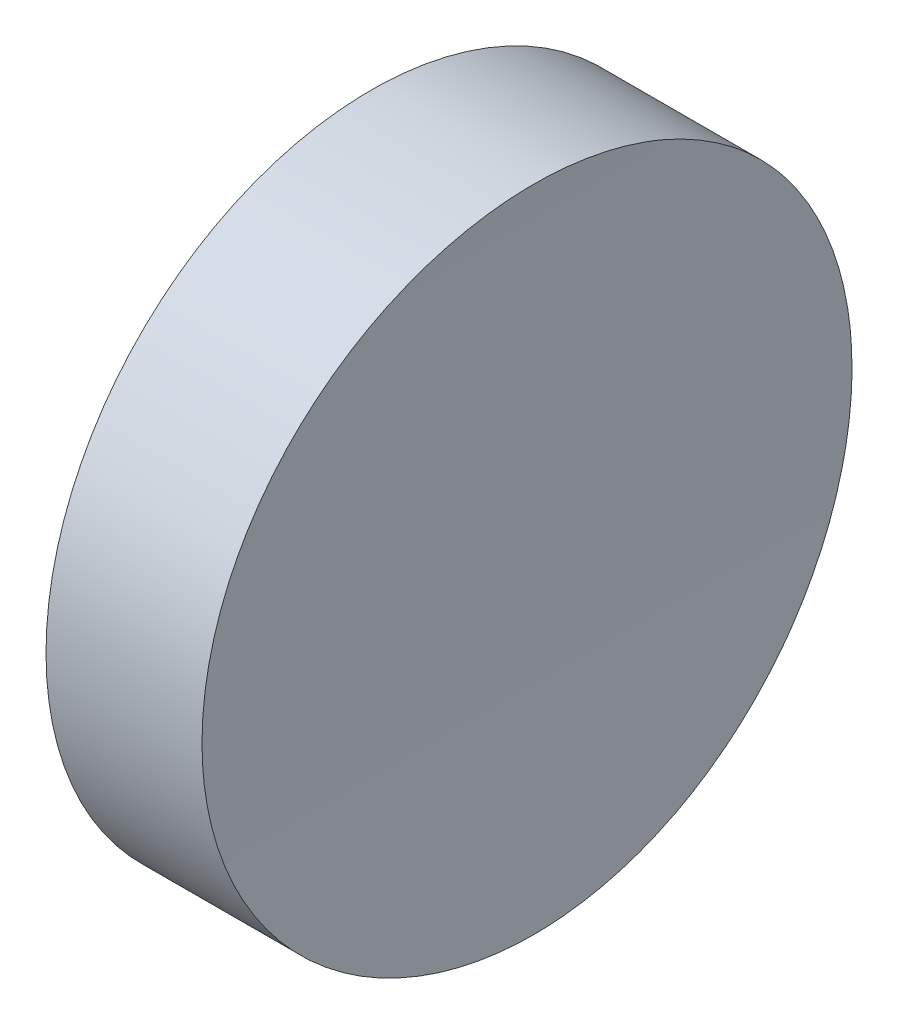
from build123d import *

# Parameters (mm, degrees)
SKETCH_1_R               = 6.25
EXTRUDE_1_DEPTH          = 10
SKETCH_2_R               = 150
CUT_EXTRUDE_1_DEPTH      = 7.25
CUT_EXTRUDE_1_DEPTH_BACK = 7.25


with BuildPart() as part:
    # 草图1 → 凸台-拉伸1 (new body)
    with BuildSketch(Plane(origin=(0, 0, 0), x_dir=(0, 0, -1), z_dir=(1, 0, 0))):
        Circle(SKETCH_1_R)
    extrude(amount=EXTRUDE_1_DEPTH)

    # 草图2 → 切除-拉伸1 (cut, two sides)
    with BuildSketch(Plane.XY) as cut_extrude_1_sk:
        with Locations((153, 0)):
            Circle(SKETCH_2_R)
    extrude(amount=CUT_EXTRUDE_1_DEPTH, mode=Mode.SUBTRACT)
    extrude(cut_extrude_1_sk.sketch, amount=-CUT_EXTRUDE_1_DEPTH_BACK, mode=Mode.SUBTRACT)


solid = part.part
